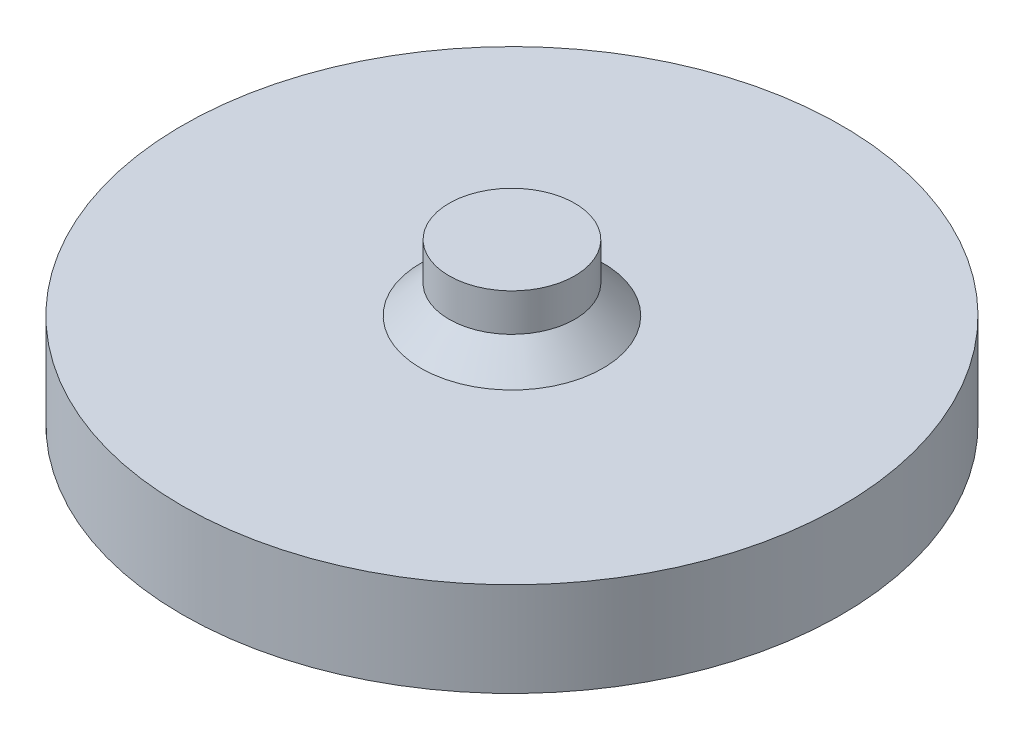
from build123d import *

# Parameters (mm, degrees)
SKETCH1_R           = 70
BOSS_EXTRUDE1_DEPTH = 20
SKETCH2_W           = 8
SKETCH2_H           = 5
CUT_EXTRUDE1_DEPTH  = 6.89
SKETCH3_R           = 13.35
BOSS_EXTRUDE2_DEPTH = 14
CHAMFER1_SIZE       = 6


with BuildPart() as part:
    # Sketch1 → Boss-Extrude1 (new body)
    with BuildSketch(Plane(origin=(0, 0, 0), x_dir=(1, 0, 0), z_dir=(0, 1, 0))):
        Circle(SKETCH1_R)
    extrude(amount=BOSS_EXTRUDE1_DEPTH)

    # Sketch2 → Cut-Extrude1 (cut)
    with BuildSketch(Plane.XZ):
        with Locations((0, 59)):
            Rectangle(SKETCH2_W, SKETCH2_H)
        Polygon((50.930435314, 24.785898385), (55.260562333, 27.285898385), (51.260562333, 34.214101615), (46.930435314, 31.714101615), align=None)
        Polygon((46.930435314, -31.714101615), (51.260562333, -34.214101615), (55.260562333, -27.285898385), (50.930435314, -24.785898385), align=None)
        Polygon((-50.930435314, -24.785898385), (-55.260562333, -27.285898385), (-51.260562333, -34.214101615), (-46.930435314, -31.714101615), align=None)
        Polygon((-46.930435314, 31.714101615), (-51.260562333, 34.214101615), (-55.260562333, 27.285898385), (-50.930435314, 24.785898385), align=None)
    extrude(amount=-CUT_EXTRUDE1_DEPTH, mode=Mode.SUBTRACT)

    # Sketch3 → Boss-Extrude2 (add)
    with BuildSketch(Plane(origin=(0, 20, 0), x_dir=(1, 0, 0), z_dir=(0, 1, 0))):
        Circle(SKETCH3_R)
    extrude(amount=BOSS_EXTRUDE2_DEPTH)

    # Chamfer1
    chamfer1_edges = [part.edges().sort_by_distance(p)[0] for p in [
        (-13.35, 20, 0),
    ]]
    chamfer(chamfer1_edges, length=CHAMFER1_SIZE)


solid = part.part
